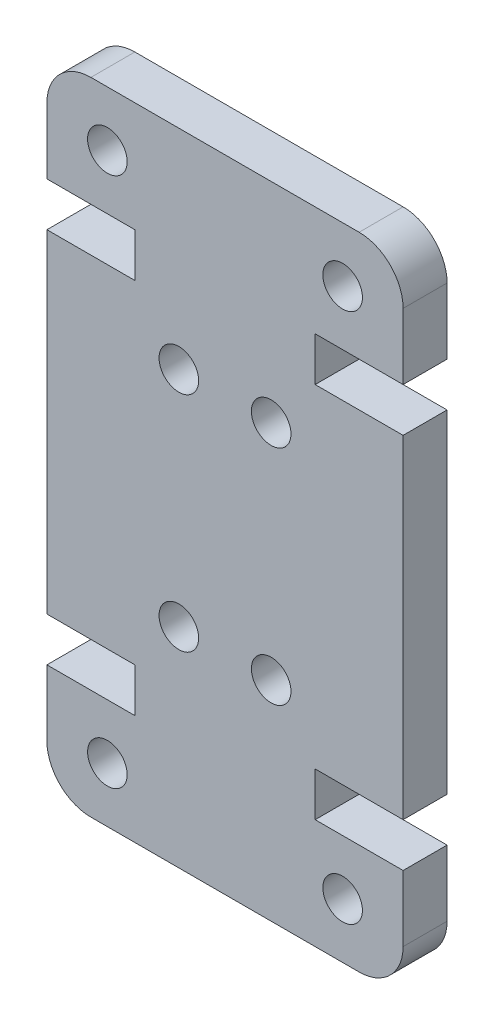
from build123d import *

# Parameters (mm, degrees)
SKETCH1_R           = 0.9
BOSS_EXTRUDE1_DEPTH = 2


with BuildPart() as part:
    # Sketch1 → Boss-Extrude1 (new body)
    with BuildSketch(Plane.XY):
        with BuildLine():
            Line((0, 22.14), (0, 7))
            Line((0, 7), (4, 7))
            Line((4, 7), (4, 5))
            Line((4, 5), (0, 5))
            Line((0, 5), (0, 2))
            ThreePointArc((0, 2), (0.585786438, 0.585786438), (2, 0))
            Line((2, 0), (14.2, 0))
            ThreePointArc((14.2, 0), (15.614213562, 0.585786438), (16.2, 2))
            Line((16.2, 2), (16.2, 5))
            Line((16.2, 5), (12.2, 5))
            Line((12.2, 5), (12.2, 7))
            Line((12.2, 7), (16.2, 7))
            Line((16.2, 7), (16.2, 22.14))
            Line((16.2, 22.14), (12.2, 22.14))
            Line((12.2, 22.14), (12.2, 24.14))
            Line((12.2, 24.14), (16.2, 24.14))
            Line((16.2, 24.14), (16.2, 27.14))
            ThreePointArc((16.2, 27.14), (15.614213562, 28.554213562), (14.2, 29.14))
            Line((14.2, 29.14), (2, 29.14))
            ThreePointArc((2, 29.14), (0.585786438, 28.554213562), (0, 27.14))
            Line((0, 27.14), (0, 24.14))
            Line((0, 24.14), (4, 24.14))
            Line((4, 24.14), (4, 22.14))
            Line((4, 22.14), (0, 22.14))
        make_face()
        with Locations((13.45, 2.5)):
            Circle(SKETCH1_R, mode=Mode.SUBTRACT)
        with Locations((10.2, 9.5)):
            Circle(SKETCH1_R, mode=Mode.SUBTRACT)
        with Locations((2.75, 26.64)):
            Circle(SKETCH1_R, mode=Mode.SUBTRACT)
        with Locations((6, 19.64)):
            Circle(SKETCH1_R, mode=Mode.SUBTRACT)
        with Locations((6, 9.5)):
            Circle(SKETCH1_R, mode=Mode.SUBTRACT)
        with Locations((2.75, 2.5)):
            Circle(SKETCH1_R, mode=Mode.SUBTRACT)
        with Locations((10.2, 19.64)):
            Circle(SKETCH1_R, mode=Mode.SUBTRACT)
        with Locations((13.45, 26.64)):
            Circle(SKETCH1_R, mode=Mode.SUBTRACT)
    extrude(amount=BOSS_EXTRUDE1_DEPTH)


solid = part.part
